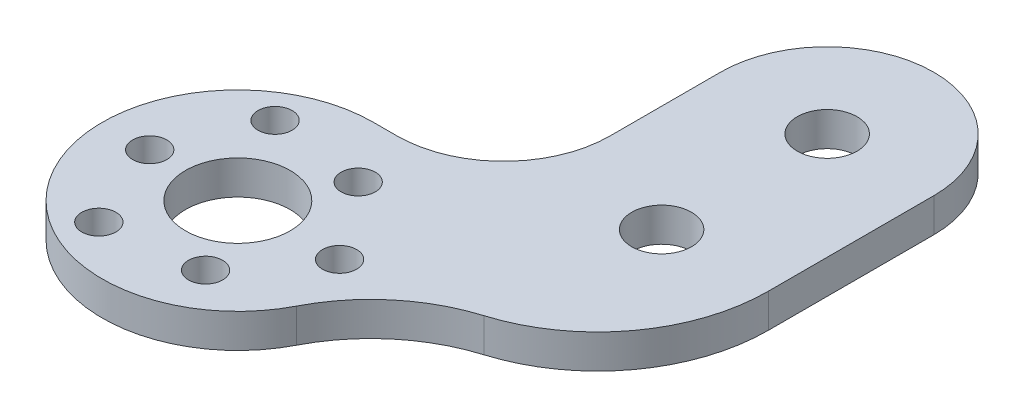
from build123d import *

# Parameters (mm, degrees)
SKETCH1_R           = 2.8
SKETCH1_R_2         = 4.9
SKETCH1_R_3         = 1.6
BOSS_EXTRUDE1_DEPTH = 3.175
CUT_EXTRUDE1_REACH  = 5.175
SKETCH3_R           = 1.6


with BuildPart() as part:
    # Sketch1 → Boss-Extrude1 (new body)
    with BuildSketch(Plane(origin=(0, 0, 0), x_dir=(1, 0, 0), z_dir=(0, 1, 0))):
        with BuildLine():
            Line((12.18, 33), (12.18, 22.7))
            ThreePointArc((12.18, 22.7), (9.251067812, 15.628932188), (2.18, 12.7))
            Line((2.18, 12.7), (0, 12.7))
            ThreePointArc((0, 12.7), (-10.837940978, -6.620350093), (11.29936434, -5.797789709))
            ThreePointArc((11.29936434, -5.797789709), (15.26781807, -0.83060398), (20.857391991, 2.198954148))
            ThreePointArc((20.857391991, 2.198954148), (29.041537075, 7.982602032), (32.18, 17.5))
            Line((32.18, 17.5), (32.18, 33))
            ThreePointArc((32.18, 33), (22.18, 43), (12.18, 33))
        make_face()
        with Locations((22.18, 17.5)):
            Circle(SKETCH1_R, mode=Mode.SUBTRACT)
        with Locations((22.18, 33)):
            Circle(SKETCH1_R, mode=Mode.SUBTRACT)
        Circle(SKETCH1_R_2, mode=Mode.SUBTRACT)
        with Locations((-8.25, 0)):
            Circle(SKETCH1_R_3, mode=Mode.SUBTRACT)
        with Locations((4.125, 7.144709581)):
            Circle(SKETCH1_R_3, mode=Mode.SUBTRACT)
        with Locations((4.125, -7.144709581)):
            Circle(SKETCH1_R_3, mode=Mode.SUBTRACT)
    extrude(amount=BOSS_EXTRUDE1_DEPTH)

    # Sketch3 → Cut-Extrude1 (cut, up to next)
    with BuildSketch(Plane(origin=(0, 3.175, 0), x_dir=(1, 0, 0), z_dir=(0, 1, 0)), mode=Mode.PRIVATE) as cut_extrude1_sk1:
        with Locations((9.526279442, 0)):
            Circle(SKETCH3_R)
    cut_extrude1_tool1 = extrude(cut_extrude1_sk1.sketch, amount=-CUT_EXTRUDE1_REACH, mode=Mode.PRIVATE) & part.part
    add(cut_extrude1_tool1.solids().sort_by_distance((9.526279, 3.175, 0))[0], mode=Mode.SUBTRACT)
    # Sketch3 → Cut-Extrude1 (cut, up to next)
    with BuildSketch(Plane(origin=(0, 3.175, 0), x_dir=(1, 0, 0), z_dir=(0, 1, 0)), mode=Mode.PRIVATE) as cut_extrude1_sk2:
        with Locations((-4.763139721, -8.25)):
            Circle(SKETCH3_R)
    cut_extrude1_tool2 = extrude(cut_extrude1_sk2.sketch, amount=-CUT_EXTRUDE1_REACH, mode=Mode.PRIVATE) & part.part
    add(cut_extrude1_tool2.solids().sort_by_distance((-4.76314, 3.175, 8.25))[0], mode=Mode.SUBTRACT)
    # Sketch3 → Cut-Extrude1 (cut, up to next)
    with BuildSketch(Plane(origin=(0, 3.175, 0), x_dir=(1, 0, 0), z_dir=(0, 1, 0)), mode=Mode.PRIVATE) as cut_extrude1_sk3:
        with Locations((-4.763139721, 8.25)):
            Circle(SKETCH3_R)
    cut_extrude1_tool3 = extrude(cut_extrude1_sk3.sketch, amount=-CUT_EXTRUDE1_REACH, mode=Mode.PRIVATE) & part.part
    add(cut_extrude1_tool3.solids().sort_by_distance((-4.76314, 3.175, -8.25))[0], mode=Mode.SUBTRACT)


solid = part.part
